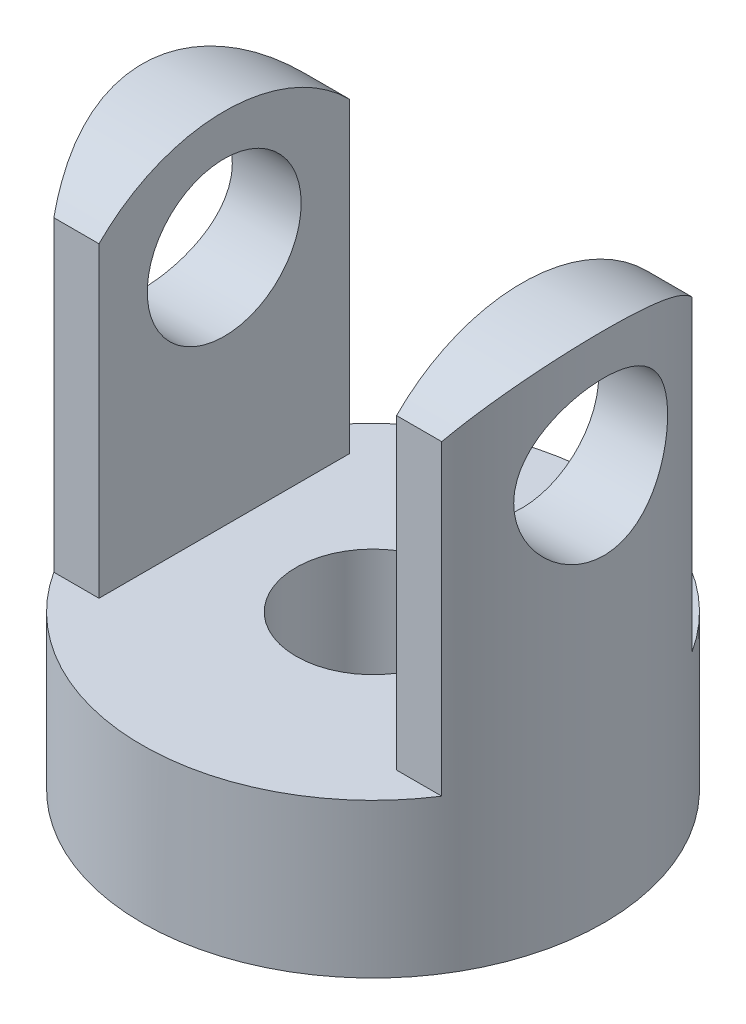
from build123d import *

# Parameters (mm, degrees)
SKETCH1_R           = 4.5
SKETCH1_R_2         = 1.5
BOSS_EXTRUDE1_DEPTH = 3
BOSS_EXTRUDE2_DEPTH = 7
SKETCH3_R           = 1.5
CUT_EXTRUDE1_DEPTH  = 6.5


with BuildPart() as part:
    # Sketch1 → Boss-Extrude1 (new body)
    with BuildSketch(Plane(origin=(0, 0, 0), x_dir=(1, 0, 0), z_dir=(0, 1, 0))):
        with Locations(Location((0, 0, 0), (0, 0, 270))):
            Circle(SKETCH1_R)
        with Locations(Location((0, 0, 0), (0, 0, 270))):
            Circle(SKETCH1_R_2, mode=Mode.SUBTRACT)
    extrude(amount=BOSS_EXTRUDE1_DEPTH)

    # Sketch2 → Boss-Extrude2 (add)
    with BuildSketch(Plane(origin=(0, 3, 0), x_dir=(1, 0, 0), z_dir=(0, 1, 0))):
        with BuildLine():
            ThreePointArc((-2.9, 3.440930107), (-4.5, 0), (-2.9, -3.440930107))
            Line((-2.9, -3.440930107), (-2.9, 3.440930107))
        make_face()
        with BuildLine():
            Line((2.9, 3.440930107), (2.9, -3.440930107))
            ThreePointArc((2.9, -3.440930107), (4.080441153, -1.897366596), (4.5, 0))
            ThreePointArc((4.5, 0), (4.080441153, 1.897366596), (2.9, 3.440930107))
        make_face()
    extrude(amount=BOSS_EXTRUDE2_DEPTH)

    # Sketch3 → Cut-Extrude1 (cut)
    with BuildSketch(Plane(origin=(-2.9, 0, 0), x_dir=(0, 0, -1), z_dir=(1, 0, 0))):
        with BuildLine():
            Line((2.440930107, 8.984324563), (2.440930107, 3))
            Line((2.440930107, 3), (3.440930107, 3))
            Line((3.440930107, 3), (3.440930107, 10))
            Line((3.440930107, 10), (0, 10))
            ThreePointArc((0, 10), (1.321905479, 9.735949794), (2.440930107, 8.984324563))
        make_face()
        with BuildLine():
            ThreePointArc((-2.440930107, 8.984324563), (-1.321905479, 9.735949794), (0, 10))
            Line((0, 10), (-3.440930107, 10))
            Line((-3.440930107, 10), (-3.440930107, 3))
            Line((-3.440930107, 3), (-2.440930107, 3))
            Line((-2.440930107, 3), (-2.440930107, 8.984324563))
        make_face()
        with Locations((0, 7.7)):
            Circle(SKETCH3_R)
    cut_extrude1 = extrude(amount=-CUT_EXTRUDE1_DEPTH, mode=Mode.SUBTRACT)

    # Mirror1: Cut-Extrude1 across plane
    add(cut_extrude1.mirror(Plane(origin=(0, 0, 0), x_dir=(0, 0, 1), z_dir=(1, 0, 0))), mode=Mode.SUBTRACT)


solid = part.part
